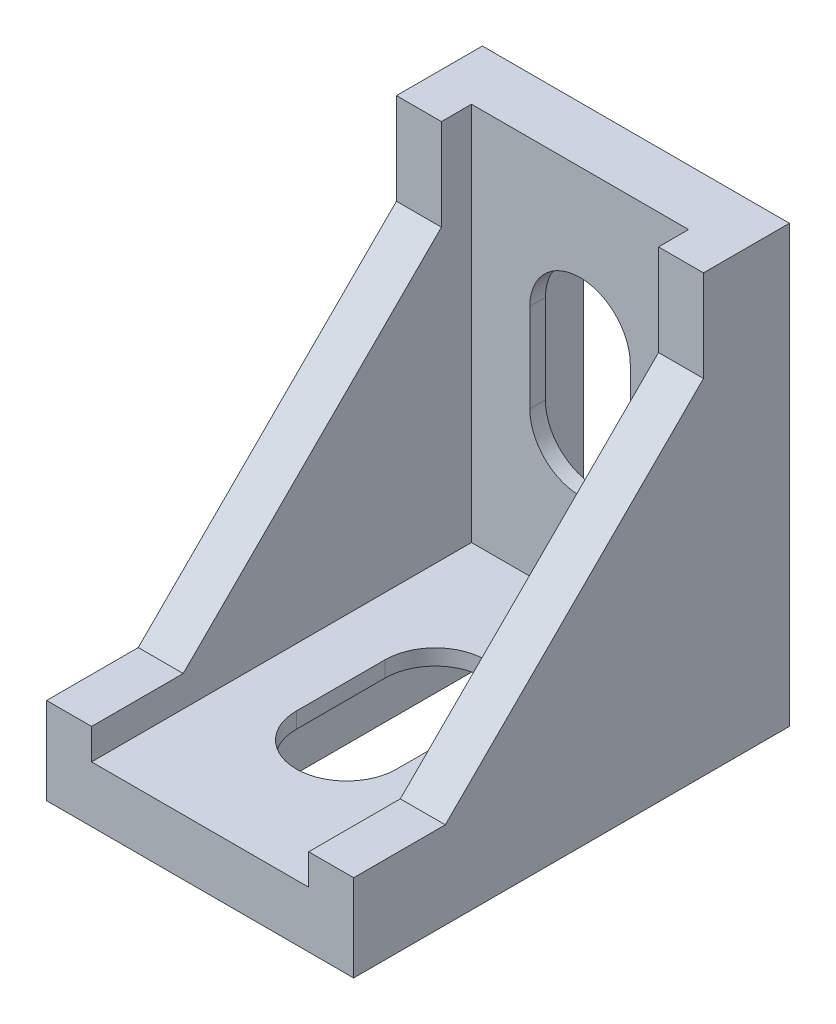
from build123d import *

# Parameters (mm, degrees)
SKETCH_1_W          = 19.8
SKETCH_1_H          = 28.1
EXTRUDE_1_DEPTH     = 3.6
SKETCH_2_W          = 2.9
SKETCH_2_H          = 28.1
EXTRUDE_2_DEPTH     = 1.94
SKETCH_3_W          = 19.8
SKETCH_3_H          = 3.62
EXTRUDE_3_DEPTH     = 27.8
SKETCH_4_W          = 2.9
SKETCH_4_H          = 5.6
EXTRUDE_4_DEPTH     = 25.86
SKETCH_5_W          = 2.9
SKETCH_5_H          = 16.6
EXTRUDE_5_DEPTH     = 16.65
CUT_EXTRUDE_1_DEPTH = 3.3
CUT_EXTRUDE_2_DEPTH = 2.9
CUT_EXTRUDE_3_DEPTH = 2.9
SKETCH_11_W         = 6.75
SKETCH_11_H         = 15.6
CUT_EXTRUDE_4_DEPTH = 2.6
CUT_EXTRUDE_5_DEPTH = 6.75
CUT_EXTRUDE_6_DEPTH = 5
SKETCH_19_W         = 4
SKETCH_19_H         = 2
EXTRUDE_7_DEPTH     = 2
CUT_EXTRUDE_7_DEPTH = 10
CUT_EXTRUDE_8_DEPTH = 10


with BuildPart() as part:
    # 草图1 → 凸台-拉伸1 (new body)
    with BuildSketch(Plane.XY):
        with Locations((9.9, -14.05)):
            Rectangle(SKETCH_1_W, SKETCH_1_H)
    extrude(amount=EXTRUDE_1_DEPTH)

    # 草图2 → 凸台-拉伸2 (add)
    with BuildSketch(Plane.XY.offset(3.6)):
        with Locations((1.45, -14.05)):
            Rectangle(SKETCH_2_W, SKETCH_2_H)
        with Locations((18.35, -14.05)):
            Rectangle(SKETCH_2_W, SKETCH_2_H)
    extrude(amount=EXTRUDE_2_DEPTH)

    # 草图3 → 凸台-拉伸3 (add)
    with BuildSketch(Plane.XY.offset(3.6)):
        with Locations((9.9, -26.29)):
            Rectangle(SKETCH_3_W, SKETCH_3_H)
    extrude(amount=EXTRUDE_3_DEPTH)

    # 草图4 → 凸台-拉伸4 (add)
    with BuildSketch(Plane.XY.offset(5.54)):
        with Locations((1.45, -25.3)):
            Rectangle(SKETCH_4_W, SKETCH_4_H)
        with Locations((18.35, -25.3)):
            Rectangle(SKETCH_4_W, SKETCH_4_H)
    extrude(amount=EXTRUDE_4_DEPTH)

    # 草图5 → 凸台-拉伸5 (add)
    with BuildSketch(Plane.XY.offset(5.54)):
        with Locations((1.45, -14.2)):
            Rectangle(SKETCH_5_W, SKETCH_5_H)
        with Locations((18.35, -14.2)):
            Rectangle(SKETCH_5_W, SKETCH_5_H)
    extrude(amount=EXTRUDE_5_DEPTH)

    # 草图6 → 切除-拉伸1 (cut)
    with BuildSketch(Plane.XY.offset(31.4)):
        Polygon((0, -22.5), (0, -28.1), (19.8, -28.1), (19.8, -22.5), (16.9, -22.5), (16.9, -24.48), (2.9, -24.48), (2.9, -22.5), align=None)
    extrude(amount=-CUT_EXTRUDE_1_DEPTH, mode=Mode.SUBTRACT)

    # 草图9 → 切除-拉伸2 (cut)
    with BuildSketch(Plane.ZY):
        Polygon((5.54, -5.9), (22.19, -5.9), (22.19, -22.5), align=None)
    extrude(amount=-CUT_EXTRUDE_2_DEPTH, mode=Mode.SUBTRACT)

    # 草图10 → 切除-拉伸3 (cut)
    with BuildSketch(Plane(origin=(19.8, 0, 0), x_dir=(0, 0, -1), z_dir=(1, 0, 0))):
        Polygon((-5.54, -5.9), (-22.19, -5.9), (-22.19, -22.5), align=None)
    extrude(amount=-CUT_EXTRUDE_3_DEPTH, mode=Mode.SUBTRACT)

    # 草图11 → 切除-拉伸4 (cut)
    with BuildSketch(Plane.XZ.offset(28.1)):
        with Locations((9.9, 15.9)):
            Rectangle(SKETCH_11_W, SKETCH_11_H)
    cut_extrude_4 = extrude(amount=-CUT_EXTRUDE_4_DEPTH, mode=Mode.SUBTRACT)

    # 草图13 → 切除-拉伸5 (cut)
    with BuildSketch(Plane.ZY.offset(-13.275)):
        Polygon((8.1, -28.1), (5.5, -28.1), (8.1, -25.5), align=None)
    cut_extrude_5 = extrude(amount=CUT_EXTRUDE_5_DEPTH, mode=Mode.SUBTRACT)

    # 镜向1: 切除-拉伸4, 切除-拉伸5 across plane
    add(cut_extrude_4.mirror(Plane(origin=(0, -14.043669746, 14.049998574), x_dir=(0, 0.707266057, 0.706947469), z_dir=(0, -0.706947469, 0.707266057))), mode=Mode.SUBTRACT)
    add(cut_extrude_5.mirror(Plane(origin=(0, -14.043669746, 14.049998574), x_dir=(0, 0.707266057, 0.706947469), z_dir=(0, -0.706947469, 0.707266057))), mode=Mode.SUBTRACT)

    # 草图16 → 切除-拉伸6 (cut)
    with BuildSketch(Plane.XZ.offset(25.5)):
        with BuildLine():
            Line((6.66, 18.66), (6.66, 12.94))
            ThreePointArc((6.66, 12.94), (9.9, 9.7), (13.14, 12.94))
            Line((13.14, 12.94), (13.14, 18.66))
            ThreePointArc((13.14, 18.66), (9.9, 21.9), (6.66, 18.66))
        make_face()
    extrude(amount=-CUT_EXTRUDE_6_DEPTH, mode=Mode.SUBTRACT)

    # 草图19 → 凸台-拉伸7 (add)
    with BuildSketch(Plane.XZ.offset(28.1)):
        with Locations((10.132631834, 4.5)):
            Rectangle(SKETCH_19_W, SKETCH_19_H)
        with Locations((10.132631834, 24.7)):
            Rectangle(SKETCH_19_W, SKETCH_19_H)
    extrude(amount=EXTRUDE_7_DEPTH)

    # 草图21 → 切除-拉伸7 (cut)
    with BuildSketch(Plane.ZY.offset(-8.132631834)):
        Polygon((5.5, -28.1), (5.5, -30.1), (3.5, -30.1), align=None)
        Polygon((25.7, -28.1), (23.7, -30.1), (25.7, -30.1), align=None)
    extrude(amount=-CUT_EXTRUDE_7_DEPTH, mode=Mode.SUBTRACT)

    # 草图23 → 切除-拉伸8 (cut)
    with BuildSketch(Plane.XY):
        with BuildLine():
            ThreePointArc((13.140089886, -9.416749042), (12.191115857, -7.125723071), (9.900089886, -6.176749042))
            Line((9.900089886, -6.176749042), (9.900089886, -9.416749042))
            Line((9.900089886, -9.416749042), (9.900089886, -11.896749042))
            ThreePointArc((9.900089886, -11.896749042), (10.684691696, -11.993184187), (11.422587833, -12.276749042))
            ThreePointArc((11.422587833, -12.276749042), (12.677723172, -11.084787808), (13.140089886, -9.416749042))
        make_face()
        with BuildLine():
            Line((9.900089886, -9.416749042), (9.900089886, -6.176749042))
            ThreePointArc((9.900089886, -6.176749042), (7.609063915, -7.125723071), (6.660089886, -9.416749042))
            ThreePointArc((6.660089886, -9.416749042), (7.122456599, -11.084787808), (8.377591938, -12.276749042))
            ThreePointArc((8.377591938, -12.276749042), (9.115488076, -11.993184187), (9.900089886, -11.896749042))
            Line((9.900089886, -11.896749042), (9.900089886, -9.416749042))
        make_face()
        with BuildLine():
            ThreePointArc((13.140089886, -9.416749042), (12.191115857, -7.125723071), (9.900089886, -6.176749042))
            Line((9.900089886, -6.176749042), (9.900089886, -9.416749042))
            Line((9.900089886, -9.416749042), (9.900089886, -11.896749042))
            ThreePointArc((9.900089886, -11.896749042), (10.684691696, -11.993184187), (11.422587833, -12.276749042))
            ThreePointArc((11.422587833, -12.276749042), (12.677723172, -11.084787808), (13.140089886, -9.416749042))
        make_face()
        with BuildLine():
            Line((9.900089886, -9.416749042), (9.900089886, -6.176749042))
            ThreePointArc((9.900089886, -6.176749042), (7.609063915, -7.125723071), (6.660089886, -9.416749042))
            ThreePointArc((6.660089886, -9.416749042), (7.122456599, -11.084787808), (8.377591938, -12.276749042))
            ThreePointArc((8.377591938, -12.276749042), (9.115488076, -11.993184187), (9.900089886, -11.896749042))
            Line((9.900089886, -11.896749042), (9.900089886, -9.416749042))
        make_face()
        with BuildLine():
            ThreePointArc((6.660089886, -15.136749042), (7.609063915, -17.427775013), (9.900089886, -18.376749042))
            Line((9.900089886, -18.376749042), (9.900089886, -15.136749042))
            Line((9.900089886, -15.136749042), (9.900089886, -12.656749042))
            ThreePointArc((9.900089886, -12.656749042), (9.115488076, -12.560313898), (8.377591938, -12.276749042))
            ThreePointArc((8.377591938, -12.276749042), (7.122456599, -13.468710276), (6.660089886, -15.136749042))
        make_face()
        with BuildLine():
            Line((9.900089886, -15.136749042), (9.900089886, -18.376749042))
            ThreePointArc((9.900089886, -18.376749042), (12.191115857, -17.427775013), (13.140089886, -15.136749042))
            ThreePointArc((13.140089886, -15.136749042), (12.677723172, -13.468710276), (11.422587833, -12.276749042))
            ThreePointArc((11.422587833, -12.276749042), (10.684691696, -12.560313898), (9.900089886, -12.656749042))
            Line((9.900089886, -12.656749042), (9.900089886, -15.136749042))
        make_face()
        with BuildLine():
            ThreePointArc((11.422587833, -12.276749042), (10.684691696, -11.993184187), (9.900089886, -11.896749042))
            Line((9.900089886, -11.896749042), (9.900089886, -12.656749042))
            ThreePointArc((9.900089886, -12.656749042), (10.684691696, -12.560313898), (11.422587833, -12.276749042))
        make_face()
        with BuildLine():
            Line((9.900089886, -12.656749042), (9.900089886, -11.896749042))
            ThreePointArc((9.900089886, -11.896749042), (9.115488076, -11.993184187), (8.377591938, -12.276749042))
            ThreePointArc((8.377591938, -12.276749042), (9.115488076, -12.560313898), (9.900089886, -12.656749042))
        make_face()
        with BuildLine():
            ThreePointArc((13.140089886, -9.416749042), (12.191115857, -7.125723071), (9.900089886, -6.176749042))
            Line((9.900089886, -6.176749042), (9.900089886, -9.416749042))
            Line((9.900089886, -9.416749042), (9.900089886, -11.896749042))
            ThreePointArc((9.900089886, -11.896749042), (10.684691696, -11.993184187), (11.422587833, -12.276749042))
            ThreePointArc((11.422587833, -12.276749042), (12.677723172, -11.084787808), (13.140089886, -9.416749042))
        make_face()
        with BuildLine():
            Line((9.900089886, -9.416749042), (9.900089886, -6.176749042))
            ThreePointArc((9.900089886, -6.176749042), (7.609063915, -7.125723071), (6.660089886, -9.416749042))
            ThreePointArc((6.660089886, -9.416749042), (7.122456599, -11.084787808), (8.377591938, -12.276749042))
            ThreePointArc((8.377591938, -12.276749042), (9.115488076, -11.993184187), (9.900089886, -11.896749042))
            Line((9.900089886, -11.896749042), (9.900089886, -9.416749042))
        make_face()
        with BuildLine():
            ThreePointArc((6.660089886, -15.136749042), (7.609063915, -17.427775013), (9.900089886, -18.376749042))
            Line((9.900089886, -18.376749042), (9.900089886, -15.136749042))
            Line((9.900089886, -15.136749042), (9.900089886, -12.656749042))
            ThreePointArc((9.900089886, -12.656749042), (9.115488076, -12.560313898), (8.377591938, -12.276749042))
            ThreePointArc((8.377591938, -12.276749042), (7.122456599, -13.468710276), (6.660089886, -15.136749042))
        make_face()
        with BuildLine():
            Line((9.900089886, -15.136749042), (9.900089886, -18.376749042))
            ThreePointArc((9.900089886, -18.376749042), (12.191115857, -17.427775013), (13.140089886, -15.136749042))
            ThreePointArc((13.140089886, -15.136749042), (12.677723172, -13.468710276), (11.422587833, -12.276749042))
            ThreePointArc((11.422587833, -12.276749042), (10.684691696, -12.560313898), (9.900089886, -12.656749042))
            Line((9.900089886, -12.656749042), (9.900089886, -15.136749042))
        make_face()
        with BuildLine():
            ThreePointArc((11.422587833, -12.276749042), (10.684691696, -11.993184187), (9.900089886, -11.896749042))
            Line((9.900089886, -11.896749042), (9.900089886, -12.656749042))
            ThreePointArc((9.900089886, -12.656749042), (10.684691696, -12.560313898), (11.422587833, -12.276749042))
        make_face()
        with BuildLine():
            Line((9.900089886, -12.656749042), (9.900089886, -11.896749042))
            ThreePointArc((9.900089886, -11.896749042), (9.115488076, -11.993184187), (8.377591938, -12.276749042))
            ThreePointArc((8.377591938, -12.276749042), (9.115488076, -12.560313898), (9.900089886, -12.656749042))
        make_face()
        with BuildLine():
            ThreePointArc((13.140089886, -9.416749042), (12.191115857, -7.125723071), (9.900089886, -6.176749042))
            Line((9.900089886, -6.176749042), (9.900089886, -9.416749042))
            Line((9.900089886, -9.416749042), (9.900089886, -11.896749042))
            ThreePointArc((9.900089886, -11.896749042), (10.684691696, -11.993184187), (11.422587833, -12.276749042))
            ThreePointArc((11.422587833, -12.276749042), (12.677723172, -11.084787808), (13.140089886, -9.416749042))
        make_face()
        with BuildLine():
            Line((9.900089886, -9.416749042), (9.900089886, -6.176749042))
            ThreePointArc((9.900089886, -6.176749042), (7.609063915, -7.125723071), (6.660089886, -9.416749042))
            ThreePointArc((6.660089886, -9.416749042), (7.122456599, -11.084787808), (8.377591938, -12.276749042))
            ThreePointArc((8.377591938, -12.276749042), (9.115488076, -11.993184187), (9.900089886, -11.896749042))
            Line((9.900089886, -11.896749042), (9.900089886, -9.416749042))
        make_face()
        with BuildLine():
            ThreePointArc((6.660089886, -15.136749042), (7.609063915, -17.427775013), (9.900089886, -18.376749042))
            Line((9.900089886, -18.376749042), (9.900089886, -15.136749042))
            Line((9.900089886, -15.136749042), (9.900089886, -12.656749042))
            ThreePointArc((9.900089886, -12.656749042), (9.115488076, -12.560313898), (8.377591938, -12.276749042))
            ThreePointArc((8.377591938, -12.276749042), (7.122456599, -13.468710276), (6.660089886, -15.136749042))
        make_face()
        with BuildLine():
            Line((9.900089886, -15.136749042), (9.900089886, -18.376749042))
            ThreePointArc((9.900089886, -18.376749042), (12.191115857, -17.427775013), (13.140089886, -15.136749042))
            ThreePointArc((13.140089886, -15.136749042), (12.677723172, -13.468710276), (11.422587833, -12.276749042))
            ThreePointArc((11.422587833, -12.276749042), (10.684691696, -12.560313898), (9.900089886, -12.656749042))
            Line((9.900089886, -12.656749042), (9.900089886, -15.136749042))
        make_face()
        with BuildLine():
            ThreePointArc((11.422587833, -12.276749042), (10.684691696, -11.993184187), (9.900089886, -11.896749042))
            Line((9.900089886, -11.896749042), (9.900089886, -12.656749042))
            ThreePointArc((9.900089886, -12.656749042), (10.684691696, -12.560313898), (11.422587833, -12.276749042))
        make_face()
        with BuildLine():
            Line((9.900089886, -12.656749042), (9.900089886, -11.896749042))
            ThreePointArc((9.900089886, -11.896749042), (9.115488076, -11.993184187), (8.377591938, -12.276749042))
            ThreePointArc((8.377591938, -12.276749042), (9.115488076, -12.560313898), (9.900089886, -12.656749042))
        make_face()
        with BuildLine():
            ThreePointArc((13.140089886, -9.416749042), (12.191115857, -7.125723071), (9.900089886, -6.176749042))
            Line((9.900089886, -6.176749042), (9.900089886, -9.416749042))
            Line((9.900089886, -9.416749042), (9.900089886, -11.896749042))
            ThreePointArc((9.900089886, -11.896749042), (10.684691696, -11.993184187), (11.422587833, -12.276749042))
            ThreePointArc((11.422587833, -12.276749042), (12.677723172, -11.084787808), (13.140089886, -9.416749042))
        make_face()
        with BuildLine():
            Line((9.900089886, -9.416749042), (9.900089886, -6.176749042))
            ThreePointArc((9.900089886, -6.176749042), (7.609063915, -7.125723071), (6.660089886, -9.416749042))
            ThreePointArc((6.660089886, -9.416749042), (7.122456599, -11.084787808), (8.377591938, -12.276749042))
            ThreePointArc((8.377591938, -12.276749042), (9.115488076, -11.993184187), (9.900089886, -11.896749042))
            Line((9.900089886, -11.896749042), (9.900089886, -9.416749042))
        make_face()
        with BuildLine():
            ThreePointArc((13.140089886, -9.416749042), (12.191115857, -7.125723071), (9.900089886, -6.176749042))
            Line((9.900089886, -6.176749042), (9.900089886, -9.416749042))
            Line((9.900089886, -9.416749042), (9.900089886, -11.896749042))
            ThreePointArc((9.900089886, -11.896749042), (10.684691696, -11.993184187), (11.422587833, -12.276749042))
            ThreePointArc((11.422587833, -12.276749042), (12.677723172, -11.084787808), (13.140089886, -9.416749042))
        make_face()
        with BuildLine():
            Line((9.900089886, -9.416749042), (9.900089886, -6.176749042))
            ThreePointArc((9.900089886, -6.176749042), (7.609063915, -7.125723071), (6.660089886, -9.416749042))
            ThreePointArc((6.660089886, -9.416749042), (7.122456599, -11.084787808), (8.377591938, -12.276749042))
            ThreePointArc((8.377591938, -12.276749042), (9.115488076, -11.993184187), (9.900089886, -11.896749042))
            Line((9.900089886, -11.896749042), (9.900089886, -9.416749042))
        make_face()
        with BuildLine():
            ThreePointArc((6.660089886, -15.136749042), (7.609063915, -17.427775013), (9.900089886, -18.376749042))
            Line((9.900089886, -18.376749042), (9.900089886, -15.136749042))
            Line((9.900089886, -15.136749042), (9.900089886, -12.656749042))
            ThreePointArc((9.900089886, -12.656749042), (9.115488076, -12.560313898), (8.377591938, -12.276749042))
            ThreePointArc((8.377591938, -12.276749042), (7.122456599, -13.468710276), (6.660089886, -15.136749042))
        make_face()
        with BuildLine():
            Line((9.900089886, -15.136749042), (9.900089886, -18.376749042))
            ThreePointArc((9.900089886, -18.376749042), (12.191115857, -17.427775013), (13.140089886, -15.136749042))
            ThreePointArc((13.140089886, -15.136749042), (12.677723172, -13.468710276), (11.422587833, -12.276749042))
            ThreePointArc((11.422587833, -12.276749042), (10.684691696, -12.560313898), (9.900089886, -12.656749042))
            Line((9.900089886, -12.656749042), (9.900089886, -15.136749042))
        make_face()
        with BuildLine():
            ThreePointArc((11.422587833, -12.276749042), (10.684691696, -11.993184187), (9.900089886, -11.896749042))
            Line((9.900089886, -11.896749042), (9.900089886, -12.656749042))
            ThreePointArc((9.900089886, -12.656749042), (10.684691696, -12.560313898), (11.422587833, -12.276749042))
        make_face()
        with BuildLine():
            Line((9.900089886, -12.656749042), (9.900089886, -11.896749042))
            ThreePointArc((9.900089886, -11.896749042), (9.115488076, -11.993184187), (8.377591938, -12.276749042))
            ThreePointArc((8.377591938, -12.276749042), (9.115488076, -12.560313898), (9.900089886, -12.656749042))
        make_face()
        with BuildLine():
            Line((13.140089886, -15.136749042), (13.140089886, -9.416749042))
            ThreePointArc((13.140089886, -9.416749042), (12.677723172, -11.084787808), (11.422587833, -12.276749042))
            ThreePointArc((11.422587833, -12.276749042), (12.677723172, -13.468710276), (13.140089886, -15.136749042))
        make_face()
        with BuildLine():
            ThreePointArc((8.377591938, -12.276749042), (7.122456599, -11.084787808), (6.660089886, -9.416749042))
            Line((6.660089886, -9.416749042), (6.660089886, -15.136749042))
            ThreePointArc((6.660089886, -15.136749042), (7.122456599, -13.468710276), (8.377591938, -12.276749042))
        make_face()
    extrude(amount=CUT_EXTRUDE_8_DEPTH, mode=Mode.SUBTRACT)


solid = part.part
